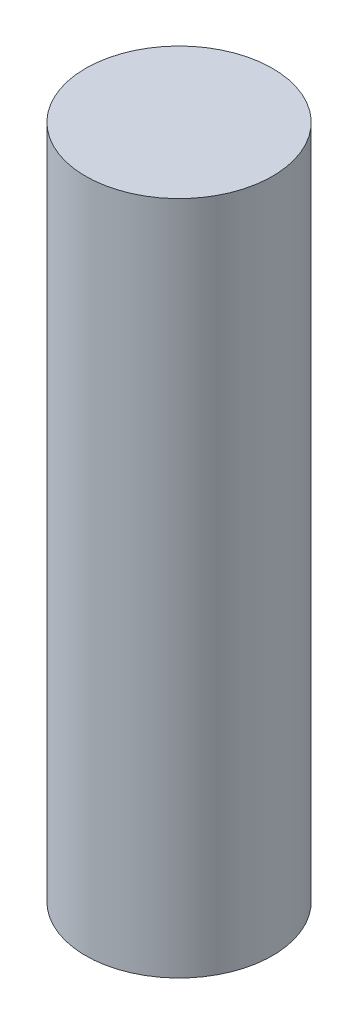
from build123d import *

# Parameters (mm, degrees)
ESBO_O1_W = 9
ESBO_O1_H = 65


with BuildPart() as part:
    # Esboço1 → Revolução1 (revolve)
    with BuildSketch(Plane.XY):
        with Locations((4.5, 32.5)):
            Rectangle(ESBO_O1_W, ESBO_O1_H)
    revolve(axis=Axis((0, 65, 0), (0, -1, 0)))


solid = part.part
